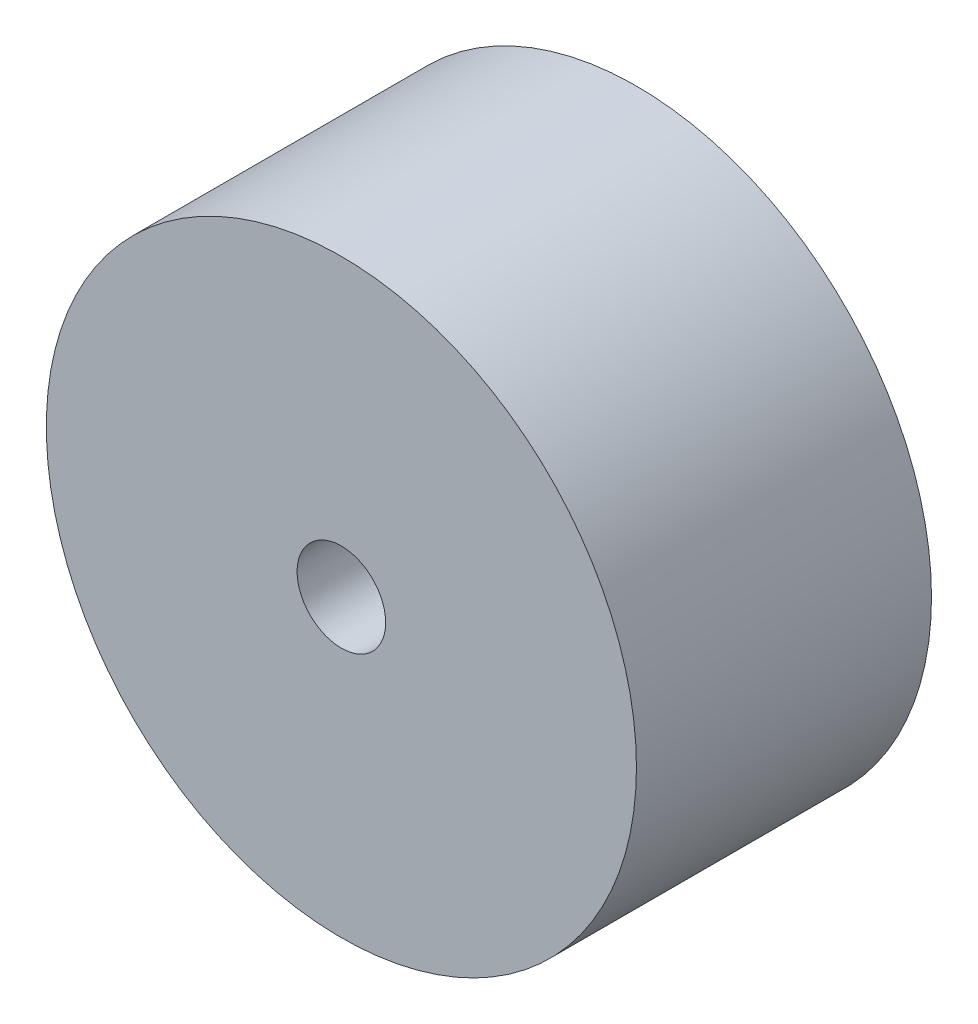
from build123d import *

# Parameters (mm, degrees)
ESQUISSE1_R        = 10
ESQUISSE1_R_2      = 1.5
BOSS_EXTRU_1_DEPTH = 10


with BuildPart() as part:
    # Esquisse1 → Boss.-Extru.1 (new body)
    with BuildSketch(Plane.XY):
        Circle(ESQUISSE1_R)
        Circle(ESQUISSE1_R_2, mode=Mode.SUBTRACT)
    extrude(amount=BOSS_EXTRU_1_DEPTH)


solid = part.part
